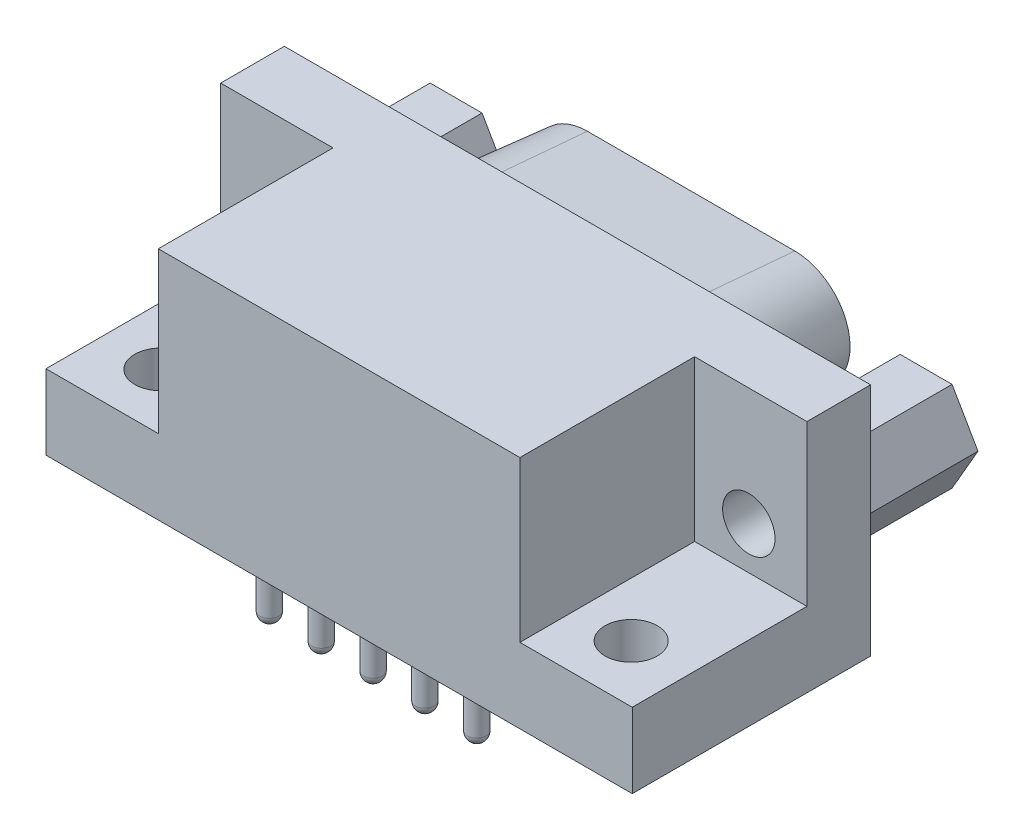
from build123d import *

# Parameters (mm, degrees)
SKETCH1_W                    = 31.314
SKETCH1_H                    = 12.55
BASE_EXTRUDE_DEPTH           = 1.77
BASE_EXTRUDE_DEPTH_BACK      = 10.96
SKETCH2_W                    = 7
SKETCH2_H                    = 10
CUT_EXTRUDE1_DEPTH           = 8.55
SKETCH4_R                    = 1.4
CUT_EXTRUDE3_DEPTH           = 26.384280569
SKETCH5_R                    = 1.4
CUT_EXTRUDE4_DEPTH           = 3
BOSS_EXTRUDE1_DEPTH          = 6.07
SKETCH7_R                    = 1.4
CUT_EXTRUDE5_DEPTH           = 6.07
BOSS_EXTRUDE3_DEPTH          = 6.07
BOSS_EXTRUDE3_TAPER          = 5
CUT_EXTRUDE7_DEPTH           = 6.07
CUT_EXTRUDE7_DRAFT           = 5
BOSS_EXTRUDE4_DEPTH          = 0.6
CUT_EXTRUDE8_START           = -0.6
SKETCH14_R                   = 0.75
CUT_EXTRUDE8_DEPTH           = 0.6
LPATTERN1_COUNT              = 4
LPATTERN1_PITCH              = 2.77
CUT_EXTRUDE9_START           = -0.6
SKETCH15_R                   = 0.75
CUT_EXTRUDE9_DEPTH           = 0.6
LPATTERN2_COUNT              = 5
LPATTERN2_PITCH              = 2.77
SKETCH16_R                   = 0.5
BOSS_EXTRUDE5_DEPTH          = 4.6
DOME1_FACE_RADIUS            = 0.5
DOME1_HEIGHT                 = 0.5
LPATTERN3_COUNT              = 4
LPATTERN3_PITCH              = 2.77
LPATTERN3_COPY_1_FACE_RADIUS = 0.5
LPATTERN3_COPY_1_HEIGHT      = 0.5
LPATTERN3_COPY_2_FACE_RADIUS = 0.5
LPATTERN3_COPY_2_HEIGHT      = 0.5
LPATTERN3_COPY_3_FACE_RADIUS = 0.5
LPATTERN3_COPY_3_HEIGHT      = 0.5
SKETCH17_R                   = 0.5
BOSS_EXTRUDE6_DEPTH          = 4.6
DOME2_FACE_RADIUS            = 0.5
DOME2_HEIGHT                 = 0.5
LPATTERN5_COUNT              = 5
LPATTERN5_PITCH              = 2.77
LPATTERN5_COPY_1_FACE_RADIUS = 0.5
LPATTERN5_COPY_1_HEIGHT      = 0.5
LPATTERN5_COPY_2_FACE_RADIUS = 0.5
LPATTERN5_COPY_2_HEIGHT      = 0.5
LPATTERN5_COPY_3_FACE_RADIUS = 0.5
LPATTERN5_COPY_3_HEIGHT      = 0.5
LPATTERN5_COPY_4_FACE_RADIUS = 0.5
LPATTERN5_COPY_4_HEIGHT      = 0.5
SKETCH18_R                   = 0.5
BOSS_EXTRUDE7_DEPTH          = 3
DOME3_FACE_RADIUS            = 0.5
DOME3_HEIGHT                 = 0.5
LPATTERN7_COUNT              = 5
LPATTERN7_PITCH              = 2.77
LPATTERN7_COPY_1_FACE_RADIUS = 0.5
LPATTERN7_COPY_1_HEIGHT      = 0.5
LPATTERN7_COPY_2_FACE_RADIUS = 0.5
LPATTERN7_COPY_2_HEIGHT      = 0.5
LPATTERN7_COPY_3_FACE_RADIUS = 0.5
LPATTERN7_COPY_3_HEIGHT      = 0.5
LPATTERN7_COPY_4_FACE_RADIUS = 0.5
LPATTERN7_COPY_4_HEIGHT      = 0.5
SKETCH19_R                   = 0.5
BOSS_EXTRUDE8_DEPTH          = 3
DOME4_FACE_RADIUS            = 0.5
DOME4_HEIGHT                 = 0.5
LPATTERN9_COUNT              = 4
LPATTERN9_PITCH              = 2.77
LPATTERN9_COPY_1_FACE_RADIUS = 0.5
LPATTERN9_COPY_1_HEIGHT      = 0.5
LPATTERN9_COPY_2_FACE_RADIUS = 0.5
LPATTERN9_COPY_2_HEIGHT      = 0.5
LPATTERN9_COPY_3_FACE_RADIUS = 0.5
LPATTERN9_COPY_3_HEIGHT      = 0.5


with BuildPart() as part:
    # Sketch1 → Base-Extrude (new, two sides)
    with BuildSketch(Plane.XY) as base_extrude_sk:
        with Locations((-5.583, 6.275)):
            Rectangle(SKETCH1_W, SKETCH1_H)
    extrude(amount=BASE_EXTRUDE_DEPTH)
    extrude(base_extrude_sk.sketch, amount=-BASE_EXTRUDE_DEPTH_BACK)

    # Sketch2 → Cut-Extrude1 (cut)
    with BuildSketch(Plane(origin=(0, 12.55, 0), x_dir=(-1, 0, 0), z_dir=(0, 1, 0))):
        with Locations((-7.574, -2.56)):
            Rectangle(SKETCH2_W, SKETCH2_H)
    cut_extrude1 = extrude(amount=-CUT_EXTRUDE1_DEPTH, mode=Mode.SUBTRACT)

    # Sketch4 → Cut-Extrude3 (cut, through all)
    with BuildSketch(Plane(origin=(0, 4, 0), x_dir=(-1, 0, 0), z_dir=(0, 1, 0))):
        with Locations(Location((-6.975, -1.27, 0), (0, 0, 90))):
            Circle(SKETCH4_R)
    cut_extrude3 = extrude(amount=-CUT_EXTRUDE3_DEPTH, mode=Mode.SUBTRACT)

    # Sketch5 → Cut-Extrude4 (cut)
    with BuildSketch(Plane.XY.offset(-7.56)):
        with Locations((6.97, 6.275)):
            Circle(SKETCH5_R)
    cut_extrude4 = extrude(amount=-CUT_EXTRUDE4_DEPTH, mode=Mode.SUBTRACT)

    # Sketch6 → Boss-Extrude1 (add)
    with BuildSketch(Plane(origin=(0, 0, -10.96), x_dir=(-1, 0, 0), z_dir=(0, 0, -1))):
        Polygon((-5.584359354, 8.675), (-8.355640646, 8.675), (-9.741281292, 6.275), (-8.355640646, 3.875), (-5.584359354, 3.875), (-4.198718708, 6.275), align=None)
    boss_extrude1 = extrude(amount=BOSS_EXTRUDE1_DEPTH)

    # Sketch7 → Cut-Extrude5 (cut)
    with BuildSketch(Plane(origin=(0, 0, -17.03), x_dir=(-1, 0, 0), z_dir=(0, 0, -1))):
        with Locations(Location((-6.97, 6.275, 0), (0, 0, 180))):
            Circle(SKETCH7_R)
    cut_extrude5 = extrude(amount=-CUT_EXTRUDE5_DEPTH, mode=Mode.SUBTRACT)

    # Mirror1: Cut-Extrude1, Cut-Extrude3, Cut-Extrude4, Boss-Extrude1, Cut-Extrude5 across plane
    add(cut_extrude1.mirror(Plane(origin=(-5.583, 0, 0), x_dir=(0, 0, 1), z_dir=(1, 0, 0))), mode=Mode.SUBTRACT)
    add(cut_extrude3.mirror(Plane(origin=(-5.583, 0, 0), x_dir=(0, 0, 1), z_dir=(1, 0, 0))), mode=Mode.SUBTRACT)
    add(cut_extrude4.mirror(Plane(origin=(-5.583, 0, 0), x_dir=(0, 0, 1), z_dir=(1, 0, 0))), mode=Mode.SUBTRACT)
    add(boss_extrude1.mirror(Plane(origin=(-5.583, 0, 0), x_dir=(0, 0, 1), z_dir=(1, 0, 0))))
    add(cut_extrude5.mirror(Plane(origin=(-5.583, 0, 0), x_dir=(0, 0, 1), z_dir=(1, 0, 0))), mode=Mode.SUBTRACT)

    # Sketch8 → Boss-Extrude3 (add)
    with BuildSketch(Plane(origin=(0, 0, -10.96), x_dir=(-1, 0, 0), z_dir=(0, 0, -1))):
        with BuildLine():
            ThreePointArc((9.738, 1.3739), (11.582769362, 1.902901897), (12.866861644, 3.329129093))
            Line((12.866861644, 3.329129093), (14.251861644, 6.169129093))
            ThreePointArc((14.251861644, 6.169129093), (14.075098103, 9.539769362), (11.123, 11.1761))
            Line((11.123, 11.1761), (0.043, 11.1761))
            ThreePointArc((0.043, 11.1761), (-2.909098103, 9.539769362), (-3.085861644, 6.169129093))
            Line((-3.085861644, 6.169129093), (-1.700861644, 3.329129093))
            ThreePointArc((-1.700861644, 3.329129093), (-0.416769362, 1.902901897), (1.428, 1.3739))
            Line((1.428, 1.3739), (9.738, 1.3739))
        make_face()
    extrude(amount=BOSS_EXTRUDE3_DEPTH, taper=BOSS_EXTRUDE3_TAPER)


with BuildPart() as cut_extrude7_tool:
    # Sketch12 → Cut-Extrude7 (with draft: the straight prism first)
    with BuildSketch(Plane(origin=(0, 0, -17.03), x_dir=(-1, 0, 0), z_dir=(0, 0, -1))):
        with BuildLine():
            Line((-2.249015246, 6.577239044), (-0.864015246, 3.737239044))
            ThreePointArc((-0.864015246, 3.737239044), (0.076633278, 2.692471057), (1.428, 2.304956188))
            Line((1.428, 2.304956188), (9.738, 2.304956188))
            ThreePointArc((9.738, 2.304956188), (11.089366722, 2.692471057), (12.030015246, 3.737239044))
            Line((12.030015246, 3.737239044), (13.415015246, 6.577239044))
            ThreePointArc((13.415015246, 6.577239044), (13.285528943, 9.046366722), (11.123, 10.245043812))
            Line((11.123, 10.245043812), (0.043, 10.245043812))
            ThreePointArc((0.043, 10.245043812), (-2.119528943, 9.046366722), (-2.249015246, 6.577239044))
        make_face()
    extrude(amount=-CUT_EXTRUDE7_DEPTH)
    # Cut-Extrude7: the draft: its side faces are tilted about the plane it starts from
    cut_extrude7_sides = [cut_extrude7_tool.faces().sort_by_distance(p)[0] for p in [
        (1.556515246, 5.157239044, -13.995),
        (-0.076633278, 2.692471057, -13.995),
        (-5.583, 2.304956188, -13.995),
        (-11.089366722, 2.692471057, -13.995),
        (-12.722515246, 5.157239044, -13.995),
        (-13.285528943, 9.046366722, -13.995),
        (-5.583, 10.245043812, -13.995),
        (2.119528943, 9.046366722, -13.995),
    ]]
    draft(cut_extrude7_sides, Plane(origin=(0, 0, -17.03), x_dir=(-1, 0, 0), z_dir=(0, 0, -1)), CUT_EXTRUDE7_DRAFT)


with BuildPart() as part_1:
    add(part.part)

    # Cut-Extrude7: cut by cut_extrude7_tool
    add(cut_extrude7_tool.part, mode=Mode.SUBTRACT)

    # Sketch13 → Boss-Extrude4 (add)
    with BuildSketch(Plane(origin=(0, 0, -10.96), x_dir=(-1, 0, 0), z_dir=(0, 0, -1))):
        with BuildLine():
            Line((-2.239987726, 6.581641549), (-0.854987726, 3.741641549))
            ThreePointArc((-0.854987726, 3.741641549), (0.081955882, 2.700988572), (1.428, 2.315))
            Line((1.428, 2.315), (9.738, 2.315))
            ThreePointArc((9.738, 2.315), (11.084044118, 2.700988572), (12.020987726, 3.741641549))
            Line((12.020987726, 3.741641549), (13.405987726, 6.581641549))
            ThreePointArc((13.405987726, 6.581641549), (13.277011428, 9.041044118), (11.123, 10.235))
            Line((11.123, 10.235), (0.043, 10.235))
            ThreePointArc((0.043, 10.235), (-2.111011428, 9.041044118), (-2.239987726, 6.581641549))
        make_face()
    extrude(amount=BOSS_EXTRUDE4_DEPTH)

    # Sketch14 → Cut-Extrude8 (cut)
    with BuildSketch(Plane(origin=(0, 0, -11.56), x_dir=(-1, 0, 0), z_dir=(0, 0, -1)).offset(CUT_EXTRUDE8_START)):
        with Locations((1.428, 4.855)):
            Circle(SKETCH14_R)
    cut_extrude8 = extrude(amount=CUT_EXTRUDE8_DEPTH, mode=Mode.SUBTRACT)

    # LPattern1: Cut-Extrude8 ×4
    with Locations(*[(-i * LPATTERN1_PITCH, 0, 0) for i in range(1, LPATTERN1_COUNT)]):
        add(cut_extrude8, mode=Mode.SUBTRACT)

    # Sketch15 → Cut-Extrude9 (cut)
    with BuildSketch(Plane(origin=(0, 0, -11.56), x_dir=(-1, 0, 0), z_dir=(0, 0, -1)).offset(CUT_EXTRUDE9_START)):
        with Locations((0.043, 7.695)):
            Circle(SKETCH15_R)
    cut_extrude9 = extrude(amount=CUT_EXTRUDE9_DEPTH, mode=Mode.SUBTRACT)

    # LPattern2: Cut-Extrude9 ×5
    with Locations(*[(-i * LPATTERN2_PITCH, 0, 0) for i in range(1, LPATTERN2_COUNT)]):
        add(cut_extrude9, mode=Mode.SUBTRACT)

    # Sketch16 → Boss-Extrude5 (add)
    with BuildSketch(Plane(origin=(0, 0, -10.96), x_dir=(-1, 0, 0), z_dir=(0, 0, -1))):
        with Locations(Location((1.428, 4.855, 0), (0, 0, 180))):
            Circle(SKETCH16_R)
    boss_extrude5 = extrude(amount=BOSS_EXTRUDE5_DEPTH)

    # Dome1: a dome of height H over a round flat face of radius A is a cap of a sphere of radius (A * A + H * H) / (2 * H)
    dome1_r = (DOME1_FACE_RADIUS * DOME1_FACE_RADIUS + DOME1_HEIGHT * DOME1_HEIGHT) / (2 * DOME1_HEIGHT)
    dome1_base = Plane((-1.428, 4.855, -15.56), z_dir=(0, 0, -1))
    with Locations(dome1_base.offset(DOME1_HEIGHT - dome1_r)):
        dome1_ball = Sphere(dome1_r, mode=Mode.PRIVATE)
    add(split(dome1_ball, bisect_by=dome1_base, keep=Keep.TOP, mode=Mode.PRIVATE))

    # LPattern3: Boss-Extrude5 ×4
    with Locations(*[(-i * LPATTERN3_PITCH, 0, 0) for i in range(1, LPATTERN3_COUNT)]):
        add(boss_extrude5)

    # LPattern3 copy 1: a dome of height H over a round flat face of radius A is a cap of a sphere of radius (A * A + H * H) / (2 * H)
    lpattern3_copy_1_r = (LPATTERN3_COPY_1_FACE_RADIUS * LPATTERN3_COPY_1_FACE_RADIUS + LPATTERN3_COPY_1_HEIGHT * LPATTERN3_COPY_1_HEIGHT) / (2 * LPATTERN3_COPY_1_HEIGHT)
    lpattern3_copy_1_base = Plane((-4.198, 4.855, -15.56), z_dir=(0, 0, -1))
    with Locations(lpattern3_copy_1_base.offset(LPATTERN3_COPY_1_HEIGHT - lpattern3_copy_1_r)):
        lpattern3_copy_1_ball = Sphere(lpattern3_copy_1_r, mode=Mode.PRIVATE)
    add(split(lpattern3_copy_1_ball, bisect_by=lpattern3_copy_1_base, keep=Keep.TOP, mode=Mode.PRIVATE))

    # LPattern3 copy 2: a dome of height H over a round flat face of radius A is a cap of a sphere of radius (A * A + H * H) / (2 * H)
    lpattern3_copy_2_r = (LPATTERN3_COPY_2_FACE_RADIUS * LPATTERN3_COPY_2_FACE_RADIUS + LPATTERN3_COPY_2_HEIGHT * LPATTERN3_COPY_2_HEIGHT) / (2 * LPATTERN3_COPY_2_HEIGHT)
    lpattern3_copy_2_base = Plane((-6.968, 4.855, -15.56), z_dir=(0, 0, -1))
    with Locations(lpattern3_copy_2_base.offset(LPATTERN3_COPY_2_HEIGHT - lpattern3_copy_2_r)):
        lpattern3_copy_2_ball = Sphere(lpattern3_copy_2_r, mode=Mode.PRIVATE)
    add(split(lpattern3_copy_2_ball, bisect_by=lpattern3_copy_2_base, keep=Keep.TOP, mode=Mode.PRIVATE))

    # LPattern3 copy 3: a dome of height H over a round flat face of radius A is a cap of a sphere of radius (A * A + H * H) / (2 * H)
    lpattern3_copy_3_r = (LPATTERN3_COPY_3_FACE_RADIUS * LPATTERN3_COPY_3_FACE_RADIUS + LPATTERN3_COPY_3_HEIGHT * LPATTERN3_COPY_3_HEIGHT) / (2 * LPATTERN3_COPY_3_HEIGHT)
    lpattern3_copy_3_base = Plane((-9.738, 4.855, -15.56), z_dir=(0, 0, -1))
    with Locations(lpattern3_copy_3_base.offset(LPATTERN3_COPY_3_HEIGHT - lpattern3_copy_3_r)):
        lpattern3_copy_3_ball = Sphere(lpattern3_copy_3_r, mode=Mode.PRIVATE)
    add(split(lpattern3_copy_3_ball, bisect_by=lpattern3_copy_3_base, keep=Keep.TOP, mode=Mode.PRIVATE))

    # Sketch17 → Boss-Extrude6 (add)
    with BuildSketch(Plane(origin=(0, 0, -10.96), x_dir=(-1, 0, 0), z_dir=(0, 0, -1))):
        with Locations(Location((0.043, 7.695, 0), (0, 0, 180))):
            Circle(SKETCH17_R)
    boss_extrude6 = extrude(amount=BOSS_EXTRUDE6_DEPTH)

    # Dome2: a dome of height H over a round flat face of radius A is a cap of a sphere of radius (A * A + H * H) / (2 * H)
    dome2_r = (DOME2_FACE_RADIUS * DOME2_FACE_RADIUS + DOME2_HEIGHT * DOME2_HEIGHT) / (2 * DOME2_HEIGHT)
    dome2_base = Plane((-0.043, 7.695, -15.56), z_dir=(0, 0, -1))
    with Locations(dome2_base.offset(DOME2_HEIGHT - dome2_r)):
        dome2_ball = Sphere(dome2_r, mode=Mode.PRIVATE)
    add(split(dome2_ball, bisect_by=dome2_base, keep=Keep.TOP, mode=Mode.PRIVATE))

    # LPattern5: Boss-Extrude6 ×5
    with Locations(*[(-i * LPATTERN5_PITCH, 0, 0) for i in range(1, LPATTERN5_COUNT)]):
        add(boss_extrude6)

    # LPattern5 copy 1: a dome of height H over a round flat face of radius A is a cap of a sphere of radius (A * A + H * H) / (2 * H)
    lpattern5_copy_1_r = (LPATTERN5_COPY_1_FACE_RADIUS * LPATTERN5_COPY_1_FACE_RADIUS + LPATTERN5_COPY_1_HEIGHT * LPATTERN5_COPY_1_HEIGHT) / (2 * LPATTERN5_COPY_1_HEIGHT)
    lpattern5_copy_1_base = Plane((-2.813, 7.695, -15.56), z_dir=(0, 0, -1))
    with Locations(lpattern5_copy_1_base.offset(LPATTERN5_COPY_1_HEIGHT - lpattern5_copy_1_r)):
        lpattern5_copy_1_ball = Sphere(lpattern5_copy_1_r, mode=Mode.PRIVATE)
    add(split(lpattern5_copy_1_ball, bisect_by=lpattern5_copy_1_base, keep=Keep.TOP, mode=Mode.PRIVATE))

    # LPattern5 copy 2: a dome of height H over a round flat face of radius A is a cap of a sphere of radius (A * A + H * H) / (2 * H)
    lpattern5_copy_2_r = (LPATTERN5_COPY_2_FACE_RADIUS * LPATTERN5_COPY_2_FACE_RADIUS + LPATTERN5_COPY_2_HEIGHT * LPATTERN5_COPY_2_HEIGHT) / (2 * LPATTERN5_COPY_2_HEIGHT)
    lpattern5_copy_2_base = Plane((-5.583, 7.695, -15.56), z_dir=(0, 0, -1))
    with Locations(lpattern5_copy_2_base.offset(LPATTERN5_COPY_2_HEIGHT - lpattern5_copy_2_r)):
        lpattern5_copy_2_ball = Sphere(lpattern5_copy_2_r, mode=Mode.PRIVATE)
    add(split(lpattern5_copy_2_ball, bisect_by=lpattern5_copy_2_base, keep=Keep.TOP, mode=Mode.PRIVATE))

    # LPattern5 copy 3: a dome of height H over a round flat face of radius A is a cap of a sphere of radius (A * A + H * H) / (2 * H)
    lpattern5_copy_3_r = (LPATTERN5_COPY_3_FACE_RADIUS * LPATTERN5_COPY_3_FACE_RADIUS + LPATTERN5_COPY_3_HEIGHT * LPATTERN5_COPY_3_HEIGHT) / (2 * LPATTERN5_COPY_3_HEIGHT)
    lpattern5_copy_3_base = Plane((-8.353, 7.695, -15.56), z_dir=(0, 0, -1))
    with Locations(lpattern5_copy_3_base.offset(LPATTERN5_COPY_3_HEIGHT - lpattern5_copy_3_r)):
        lpattern5_copy_3_ball = Sphere(lpattern5_copy_3_r, mode=Mode.PRIVATE)
    add(split(lpattern5_copy_3_ball, bisect_by=lpattern5_copy_3_base, keep=Keep.TOP, mode=Mode.PRIVATE))

    # LPattern5 copy 4: a dome of height H over a round flat face of radius A is a cap of a sphere of radius (A * A + H * H) / (2 * H)
    lpattern5_copy_4_r = (LPATTERN5_COPY_4_FACE_RADIUS * LPATTERN5_COPY_4_FACE_RADIUS + LPATTERN5_COPY_4_HEIGHT * LPATTERN5_COPY_4_HEIGHT) / (2 * LPATTERN5_COPY_4_HEIGHT)
    lpattern5_copy_4_base = Plane((-11.123, 7.695, -15.56), z_dir=(0, 0, -1))
    with Locations(lpattern5_copy_4_base.offset(LPATTERN5_COPY_4_HEIGHT - lpattern5_copy_4_r)):
        lpattern5_copy_4_ball = Sphere(lpattern5_copy_4_r, mode=Mode.PRIVATE)
    add(split(lpattern5_copy_4_ball, bisect_by=lpattern5_copy_4_base, keep=Keep.TOP, mode=Mode.PRIVATE))

    # Sketch18 → Boss-Extrude7 (add)
    with BuildSketch(Plane.XZ):
        with Locations(Location((0, 0, 0), (0, 0, 90))):
            Circle(SKETCH18_R)
    boss_extrude7 = extrude(amount=BOSS_EXTRUDE7_DEPTH)

    # Dome3: a dome of height H over a round flat face of radius A is a cap of a sphere of radius (A * A + H * H) / (2 * H)
    dome3_r = (DOME3_FACE_RADIUS * DOME3_FACE_RADIUS + DOME3_HEIGHT * DOME3_HEIGHT) / (2 * DOME3_HEIGHT)
    dome3_base = Plane((0, -3, 0), z_dir=(0, -1, 0))
    with Locations(dome3_base.offset(DOME3_HEIGHT - dome3_r)):
        dome3_ball = Sphere(dome3_r, mode=Mode.PRIVATE)
    add(split(dome3_ball, bisect_by=dome3_base, keep=Keep.TOP, mode=Mode.PRIVATE))

    # LPattern7: Boss-Extrude7 ×5
    with Locations(*[(-i * LPATTERN7_PITCH, 0, 0) for i in range(1, LPATTERN7_COUNT)]):
        add(boss_extrude7)

    # LPattern7 copy 1: a dome of height H over a round flat face of radius A is a cap of a sphere of radius (A * A + H * H) / (2 * H)
    lpattern7_copy_1_r = (LPATTERN7_COPY_1_FACE_RADIUS * LPATTERN7_COPY_1_FACE_RADIUS + LPATTERN7_COPY_1_HEIGHT * LPATTERN7_COPY_1_HEIGHT) / (2 * LPATTERN7_COPY_1_HEIGHT)
    lpattern7_copy_1_base = Plane((-2.77, -3, 0), z_dir=(0, -1, 0))
    with Locations(lpattern7_copy_1_base.offset(LPATTERN7_COPY_1_HEIGHT - lpattern7_copy_1_r)):
        lpattern7_copy_1_ball = Sphere(lpattern7_copy_1_r, mode=Mode.PRIVATE)
    add(split(lpattern7_copy_1_ball, bisect_by=lpattern7_copy_1_base, keep=Keep.TOP, mode=Mode.PRIVATE))

    # LPattern7 copy 2: a dome of height H over a round flat face of radius A is a cap of a sphere of radius (A * A + H * H) / (2 * H)
    lpattern7_copy_2_r = (LPATTERN7_COPY_2_FACE_RADIUS * LPATTERN7_COPY_2_FACE_RADIUS + LPATTERN7_COPY_2_HEIGHT * LPATTERN7_COPY_2_HEIGHT) / (2 * LPATTERN7_COPY_2_HEIGHT)
    lpattern7_copy_2_base = Plane((-5.54, -3, 0), z_dir=(0, -1, 0))
    with Locations(lpattern7_copy_2_base.offset(LPATTERN7_COPY_2_HEIGHT - lpattern7_copy_2_r)):
        lpattern7_copy_2_ball = Sphere(lpattern7_copy_2_r, mode=Mode.PRIVATE)
    add(split(lpattern7_copy_2_ball, bisect_by=lpattern7_copy_2_base, keep=Keep.TOP, mode=Mode.PRIVATE))

    # LPattern7 copy 3: a dome of height H over a round flat face of radius A is a cap of a sphere of radius (A * A + H * H) / (2 * H)
    lpattern7_copy_3_r = (LPATTERN7_COPY_3_FACE_RADIUS * LPATTERN7_COPY_3_FACE_RADIUS + LPATTERN7_COPY_3_HEIGHT * LPATTERN7_COPY_3_HEIGHT) / (2 * LPATTERN7_COPY_3_HEIGHT)
    lpattern7_copy_3_base = Plane((-8.31, -3, 0), z_dir=(0, -1, 0))
    with Locations(lpattern7_copy_3_base.offset(LPATTERN7_COPY_3_HEIGHT - lpattern7_copy_3_r)):
        lpattern7_copy_3_ball = Sphere(lpattern7_copy_3_r, mode=Mode.PRIVATE)
    add(split(lpattern7_copy_3_ball, bisect_by=lpattern7_copy_3_base, keep=Keep.TOP, mode=Mode.PRIVATE))

    # LPattern7 copy 4: a dome of height H over a round flat face of radius A is a cap of a sphere of radius (A * A + H * H) / (2 * H)
    lpattern7_copy_4_r = (LPATTERN7_COPY_4_FACE_RADIUS * LPATTERN7_COPY_4_FACE_RADIUS + LPATTERN7_COPY_4_HEIGHT * LPATTERN7_COPY_4_HEIGHT) / (2 * LPATTERN7_COPY_4_HEIGHT)
    lpattern7_copy_4_base = Plane((-11.08, -3, 0), z_dir=(0, -1, 0))
    with Locations(lpattern7_copy_4_base.offset(LPATTERN7_COPY_4_HEIGHT - lpattern7_copy_4_r)):
        lpattern7_copy_4_ball = Sphere(lpattern7_copy_4_r, mode=Mode.PRIVATE)
    add(split(lpattern7_copy_4_ball, bisect_by=lpattern7_copy_4_base, keep=Keep.TOP, mode=Mode.PRIVATE))

    # Sketch19 → Boss-Extrude8 (add)
    with BuildSketch(Plane.XZ):
        with Locations(Location((-1.38, -2.84, 0), (0, 0, 90))):
            Circle(SKETCH19_R)
    boss_extrude8 = extrude(amount=BOSS_EXTRUDE8_DEPTH)

    # Dome4: a dome of height H over a round flat face of radius A is a cap of a sphere of radius (A * A + H * H) / (2 * H)
    dome4_r = (DOME4_FACE_RADIUS * DOME4_FACE_RADIUS + DOME4_HEIGHT * DOME4_HEIGHT) / (2 * DOME4_HEIGHT)
    dome4_base = Plane((-1.38, -3, -2.84), z_dir=(0, -1, 0))
    with Locations(dome4_base.offset(DOME4_HEIGHT - dome4_r)):
        dome4_ball = Sphere(dome4_r, mode=Mode.PRIVATE)
    add(split(dome4_ball, bisect_by=dome4_base, keep=Keep.TOP, mode=Mode.PRIVATE))

    # LPattern9: Boss-Extrude8 ×4
    with Locations(*[(-i * LPATTERN9_PITCH, 0, 0) for i in range(1, LPATTERN9_COUNT)]):
        add(boss_extrude8)

    # LPattern9 copy 1: a dome of height H over a round flat face of radius A is a cap of a sphere of radius (A * A + H * H) / (2 * H)
    lpattern9_copy_1_r = (LPATTERN9_COPY_1_FACE_RADIUS * LPATTERN9_COPY_1_FACE_RADIUS + LPATTERN9_COPY_1_HEIGHT * LPATTERN9_COPY_1_HEIGHT) / (2 * LPATTERN9_COPY_1_HEIGHT)
    lpattern9_copy_1_base = Plane((-4.15, -3, -2.84), z_dir=(0, -1, 0))
    with Locations(lpattern9_copy_1_base.offset(LPATTERN9_COPY_1_HEIGHT - lpattern9_copy_1_r)):
        lpattern9_copy_1_ball = Sphere(lpattern9_copy_1_r, mode=Mode.PRIVATE)
    add(split(lpattern9_copy_1_ball, bisect_by=lpattern9_copy_1_base, keep=Keep.TOP, mode=Mode.PRIVATE))

    # LPattern9 copy 2: a dome of height H over a round flat face of radius A is a cap of a sphere of radius (A * A + H * H) / (2 * H)
    lpattern9_copy_2_r = (LPATTERN9_COPY_2_FACE_RADIUS * LPATTERN9_COPY_2_FACE_RADIUS + LPATTERN9_COPY_2_HEIGHT * LPATTERN9_COPY_2_HEIGHT) / (2 * LPATTERN9_COPY_2_HEIGHT)
    lpattern9_copy_2_base = Plane((-6.92, -3, -2.84), z_dir=(0, -1, 0))
    with Locations(lpattern9_copy_2_base.offset(LPATTERN9_COPY_2_HEIGHT - lpattern9_copy_2_r)):
        lpattern9_copy_2_ball = Sphere(lpattern9_copy_2_r, mode=Mode.PRIVATE)
    add(split(lpattern9_copy_2_ball, bisect_by=lpattern9_copy_2_base, keep=Keep.TOP, mode=Mode.PRIVATE))

    # LPattern9 copy 3: a dome of height H over a round flat face of radius A is a cap of a sphere of radius (A * A + H * H) / (2 * H)
    lpattern9_copy_3_r = (LPATTERN9_COPY_3_FACE_RADIUS * LPATTERN9_COPY_3_FACE_RADIUS + LPATTERN9_COPY_3_HEIGHT * LPATTERN9_COPY_3_HEIGHT) / (2 * LPATTERN9_COPY_3_HEIGHT)
    lpattern9_copy_3_base = Plane((-9.69, -3, -2.84), z_dir=(0, -1, 0))
    with Locations(lpattern9_copy_3_base.offset(LPATTERN9_COPY_3_HEIGHT - lpattern9_copy_3_r)):
        lpattern9_copy_3_ball = Sphere(lpattern9_copy_3_r, mode=Mode.PRIVATE)
    add(split(lpattern9_copy_3_ball, bisect_by=lpattern9_copy_3_base, keep=Keep.TOP, mode=Mode.PRIVATE))


solid = part_1.part
